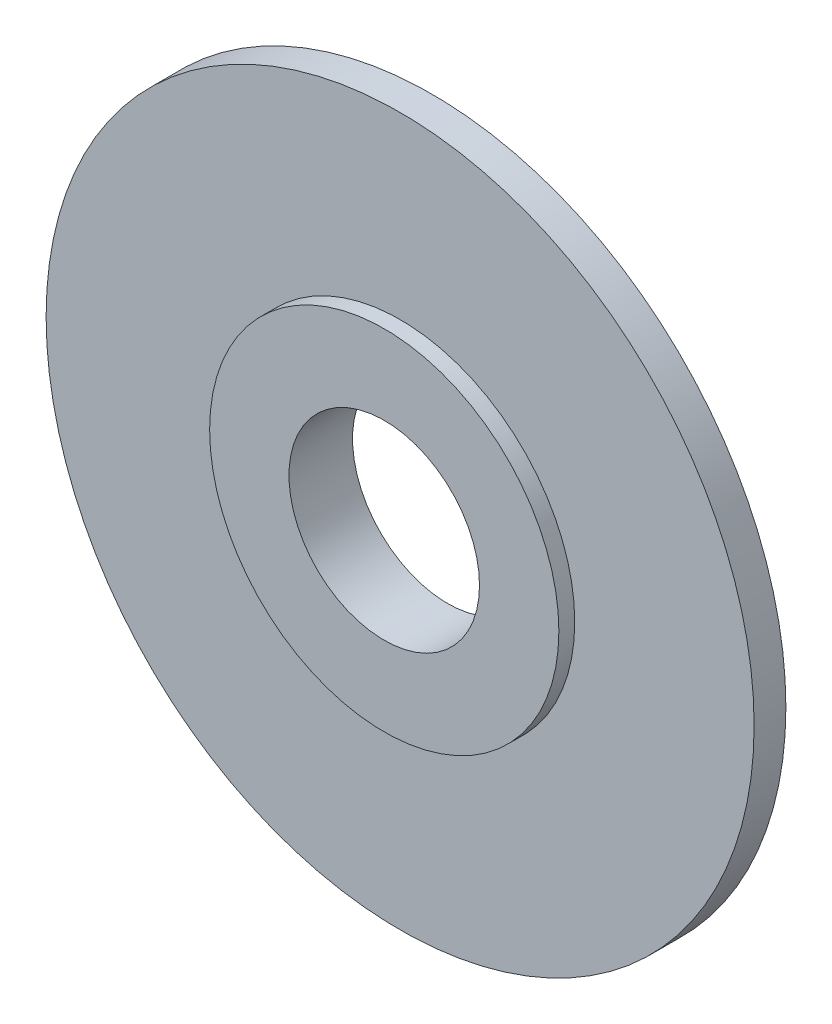
from build123d import *

# Parameters (mm, degrees)
SKETCH1_R                = 27.5
SKETCH1_R_2              = 15
BOSS_EXTRUDE1_DEPTH      = 10
SKETCH2_R                = 55.75
SKETCH2_R_2              = 27.5
BOSS_EXTRUDE2_DEPTH      = 2.5
BOSS_EXTRUDE2_DEPTH_BACK = 2.5


with BuildPart() as part:
    # Sketch1 → Boss-Extrude1 (new body)
    with BuildSketch(Plane.XY):
        Circle(SKETCH1_R)
        Circle(SKETCH1_R_2, mode=Mode.SUBTRACT)
    extrude(amount=BOSS_EXTRUDE1_DEPTH)

    # Sketch2 → Boss-Extrude2 (add, two sides)
    with BuildSketch(Plane.XY.offset(5)) as boss_extrude2_sk:
        Circle(SKETCH2_R)
        Circle(SKETCH2_R_2, mode=Mode.SUBTRACT)
    extrude(amount=BOSS_EXTRUDE2_DEPTH)
    extrude(boss_extrude2_sk.sketch, amount=-BOSS_EXTRUDE2_DEPTH_BACK)


solid = part.part
